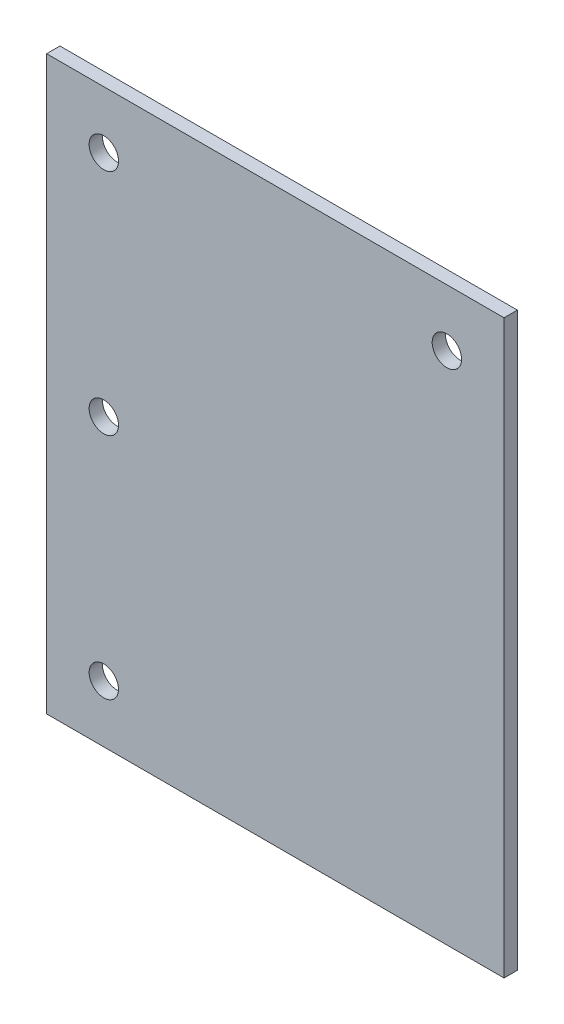
from build123d import *

# Parameters (mm, degrees)
SKETCH1_W                   = 101.6
SKETCH1_H                   = 127
BOSS_EXTRUDE1_DEPTH         = 2.9591
F_1_4_CLEARANCE_HOLE1_D     = 6.5278
F_1_4_CLEARANCE_HOLE1_DEPTH = 3.302
F_1_4_CLEARANCE_HOLE1_TIP   = 1.961148974


with BuildPart() as part:
    # Sketch1 → Boss-Extrude1 (new body)
    with BuildSketch(Plane.XY):
        Rectangle(SKETCH1_W, SKETCH1_H)
    extrude(amount=BOSS_EXTRUDE1_DEPTH)

    # 1/4 Clearance Hole1
    with Locations(Plane.XY.offset(2.9591)):
        with Locations((-38.1, 50.8), (38.1, 50.8), (-38.1, -50.8), (-38.1, 0)):
            Hole(F_1_4_CLEARANCE_HOLE1_D / 2, depth=F_1_4_CLEARANCE_HOLE1_DEPTH)
            with Locations((0, 0, -(F_1_4_CLEARANCE_HOLE1_DEPTH + F_1_4_CLEARANCE_HOLE1_TIP / 2))):  # 118° drill point
                Cone(0, F_1_4_CLEARANCE_HOLE1_D / 2, F_1_4_CLEARANCE_HOLE1_TIP, mode=Mode.SUBTRACT)


solid = part.part
